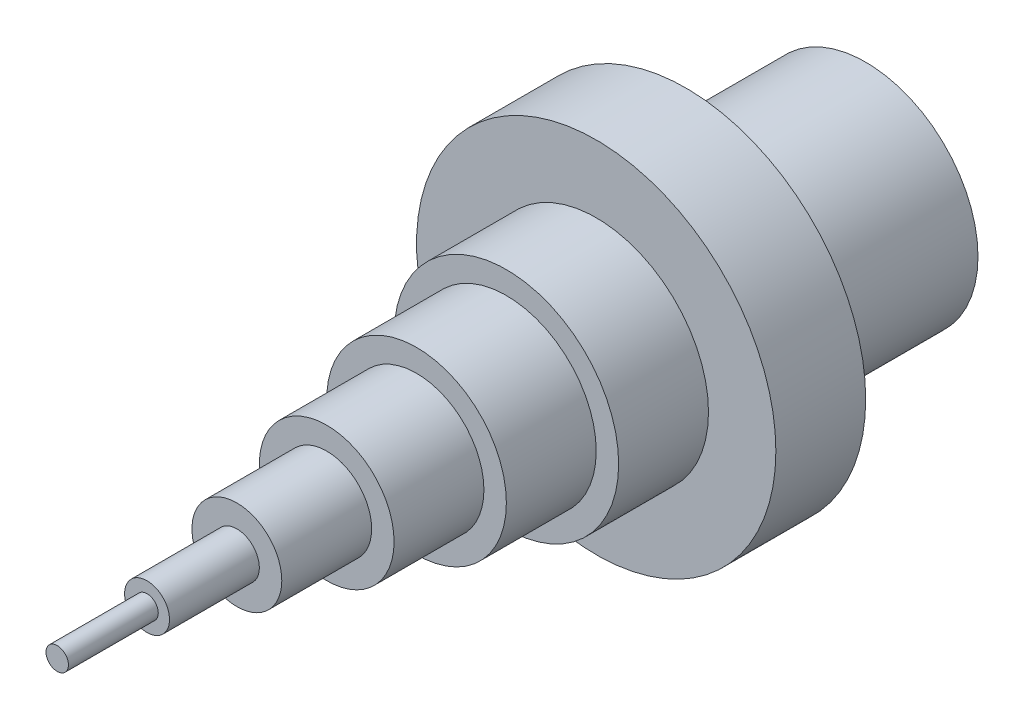
from build123d import *

# Parameters (mm, degrees)
SKETCH3_R          = 20
CUT_EXTRUDE1_DEPTH = 40


with BuildPart() as part:
    # Sketch1 → Revolve1 (revolve)
    with BuildSketch(Plane(origin=(0, 0, 0), x_dir=(1, 0, 0), z_dir=(0, 1, 0))):
        Polygon((0, 0), (2.5, 0), (2.5, 20), (5, 20), (5, 40), (10, 40), (10, 60), (15, 60), (15, 80), (20, 80), (20, 100), (25, 100), (25, 120), (40, 120), (40, 140), (25, 140), (25, 180), (0, 180), align=None)
    revolve(axis=Axis((0, 0, 0), (0, 0, -1)))

    # Sketch3 → Cut-Extrude1 (cut)
    with BuildSketch(Plane(origin=(0, 0, -180), x_dir=(-1, 0, 0), z_dir=(0, 0, -1))):
        with Locations(Location((0, 0, 0), (0, 0, 180))):  # turned: the seam where the file's is
            Circle(SKETCH3_R)
    extrude(amount=-CUT_EXTRUDE1_DEPTH, mode=Mode.SUBTRACT)


solid = part.part
